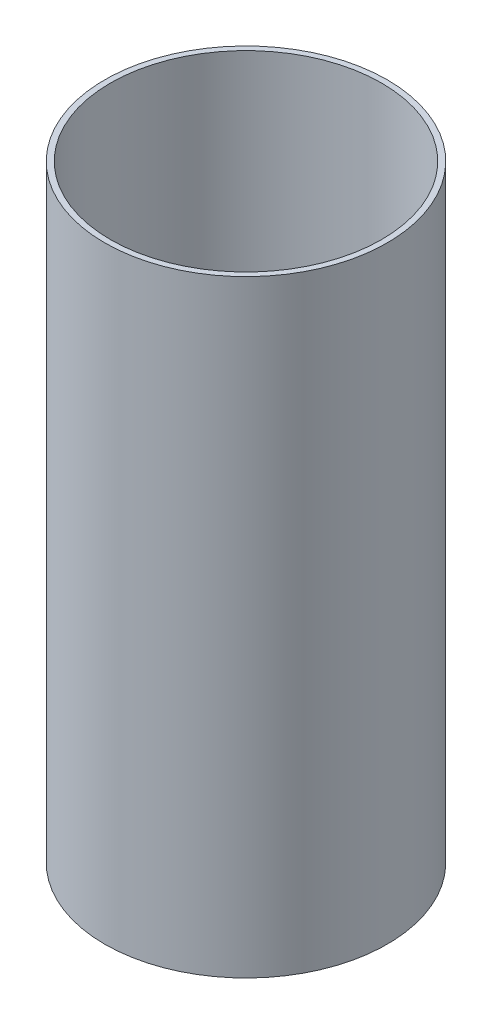
from build123d import *

# Parameters (mm, degrees)
SKETCH1_R           = 38.1
SKETCH1_R_2         = 36.576
BOSS_EXTRUDE1_DEPTH = 81.915
SKETCH2_R           = 6.985
CUT_EXTRUDE1_DEPTH  = 6.35


with BuildPart() as part:
    # Sketch1 → Boss-Extrude1 (new body, symmetric)
    with BuildSketch(Plane(origin=(0, 0, 0), x_dir=(1, 0, 0), z_dir=(0, 1, 0))):
        Circle(SKETCH1_R)
        Circle(SKETCH1_R_2, mode=Mode.SUBTRACT)
    extrude(amount=BOSS_EXTRUDE1_DEPTH, both=True)

    # Sketch2 → Cut-Extrude1 (cut)
    with BuildSketch(Plane.ZY.offset(38.1)):
        with Locations((0, 9.525)):
            Circle(SKETCH2_R)
    extrude(amount=-CUT_EXTRUDE1_DEPTH, mode=Mode.SUBTRACT)


solid = part.part
